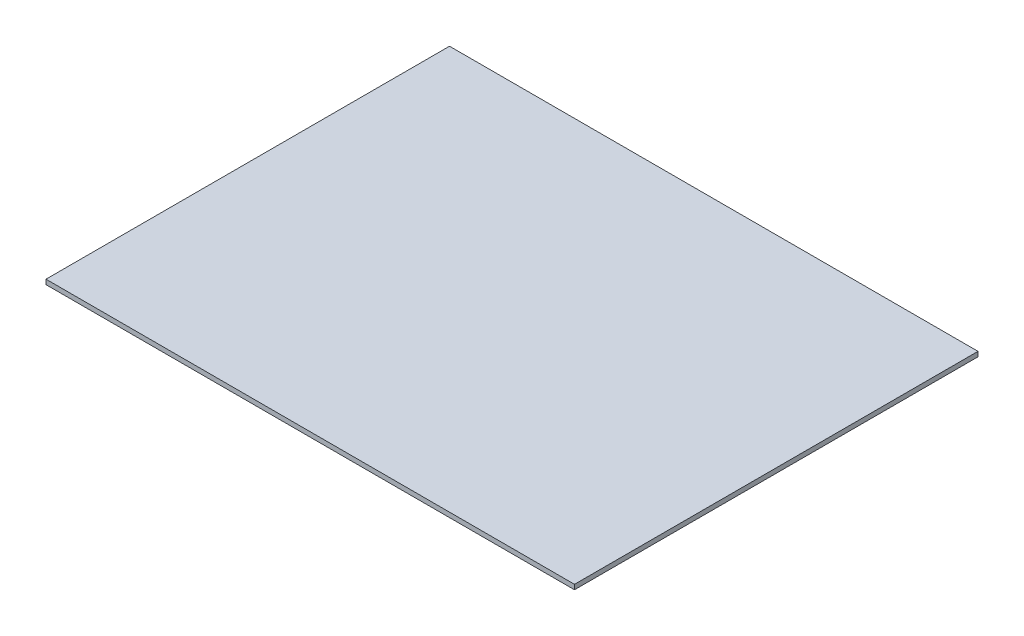
from build123d import *

# Parameters (mm, degrees)
SKETCH_1_W      = 444
SKETCH_1_H      = 339
EXTRUDE_1_DEPTH = 4


with BuildPart() as part:
    # Эскиз1 → Бобышка-Вытянуть1 (new body)
    with BuildSketch(Plane(origin=(0, 0, 0), x_dir=(1, 0, 0), z_dir=(0, 1, 0))):
        Rectangle(SKETCH_1_W, SKETCH_1_H)
    extrude(amount=EXTRUDE_1_DEPTH)


solid = part.part
